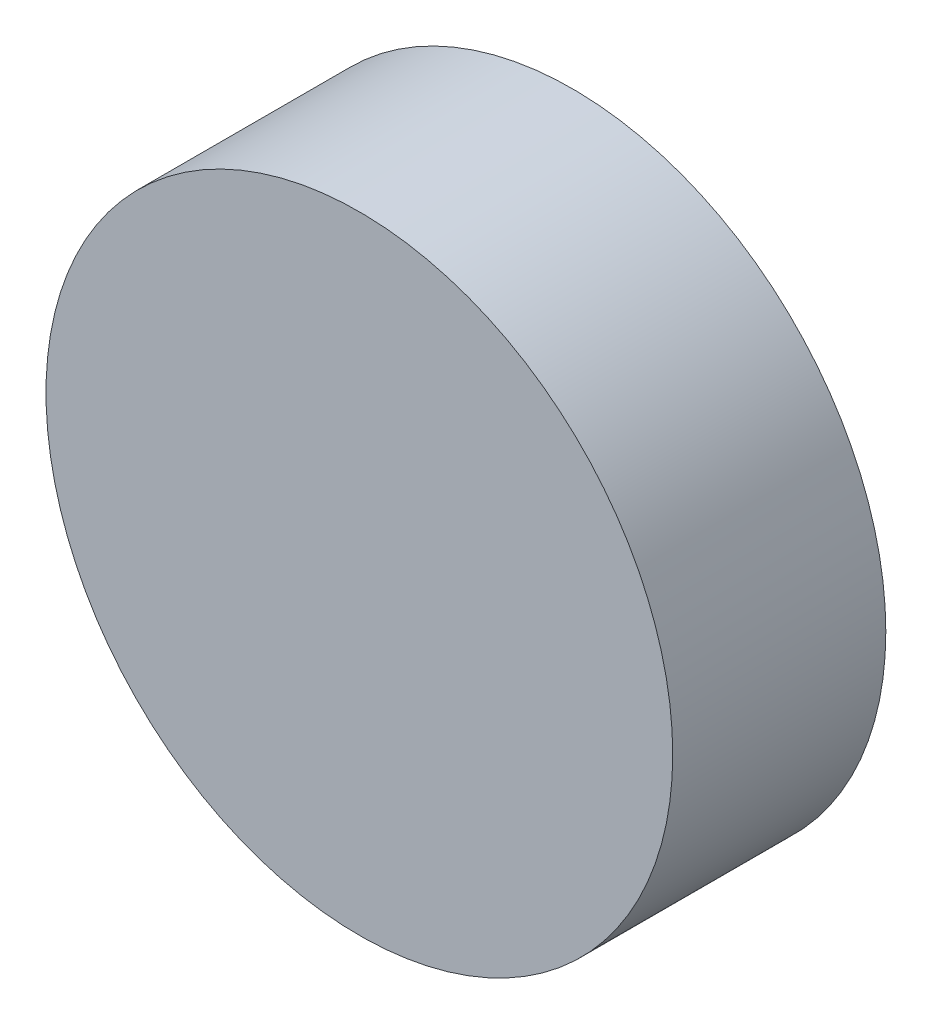
from build123d import *

# Parameters (mm, degrees)
SKETCH1_R           = 25
BOSS_EXTRUDE1_DEPTH = 17
CIRPATTERN1_COUNT   = 3
SKETCH14_W          = 15.649879363
SKETCH14_H          = 14
CUT_EXTRUDE2_DEPTH  = 17.25
CUT_EXTRUDE3_DEPTH  = 15
SKETCH16_R          = 2
SKETCH16_R_2        = 1
BOSS_EXTRUDE2_DEPTH = 3


with BuildPart() as part:
    # Sketch1 → Boss-Extrude1 (new body)
    with BuildSketch(Plane.XY):
        Circle(SKETCH1_R)
    extrude(amount=BOSS_EXTRUDE1_DEPTH)

    # Sketch12 → Ø3.0mm Dowel Hole1 (revolve, cut)
    with BuildSketch(Plane(origin=(0, 21, 0), x_dir=(0, 1, 0), z_dir=(1, 0, 0))):
        Polygon((0, 0), (0, 5.901290929), (1.5, 5), (1.5, 0), align=None)
    f_3_0mm_dowel_hole1 = revolve(axis=Axis((0, 21, -6.35), (0, 0, 1)), mode=Mode.SUBTRACT)

    # CirPattern1: Ø3.0mm Dowel Hole1 ×3 about axis
    cirpattern1_axis = Axis((0, 0, 0), (0, 0, 1))
    for i in range(1, CIRPATTERN1_COUNT):
        add(f_3_0mm_dowel_hole1.rotate(cirpattern1_axis, i * 360 / CIRPATTERN1_COUNT), mode=Mode.SUBTRACT)

    # Sketch14 → Cut-Extrude2 (cut)
    with BuildSketch(Plane(origin=(0, -25, 0), x_dir=(-1, 0, 0), z_dir=(0, -1, 0))):
        with Locations((-0.842506508, -8.397851159)):
            Rectangle(SKETCH14_W, SKETCH14_H)
    extrude(amount=-CUT_EXTRUDE2_DEPTH, mode=Mode.SUBTRACT)

    # Sketch15 → Cut-Extrude3 (cut)
    with BuildSketch(Plane(origin=(0, 0, 0), x_dir=(-1, 0, 0), z_dir=(0, 0, -1))):
        with BuildLine():
            ThreePointArc((-3.981818088, 20.619047619), (0, 17), (3.981818088, 20.619047619))
            ThreePointArc((3.981818088, 20.619047619), (18.186533479, 10.5), (19.847528084, -6.861168192))
            ThreePointArc((19.847528084, -6.861168192), (14.722431864, -8.5), (15.865709996, -13.757879427))
            ThreePointArc((15.865709996, -13.757879427), (0, -21), (-15.865709996, -13.757879427))
            ThreePointArc((-15.865709996, -13.757879427), (-14.722431864, -8.5), (-19.847528084, -6.861168192))
            ThreePointArc((-19.847528084, -6.861168192), (-18.186533479, 10.5), (-3.981818088, 20.619047619))
        make_face()
    extrude(amount=-CUT_EXTRUDE3_DEPTH, mode=Mode.SUBTRACT)

    # Sketch16 → Boss-Extrude2 (add)
    with BuildSketch(Plane(origin=(0, 0, 15), x_dir=(-1, 0, 0), z_dir=(0, 0, -1))):
        with Locations((-7, 8.038832814)):
            Circle(SKETCH16_R)
        with Locations((-7, 8.038832814)):
            Circle(SKETCH16_R_2, mode=Mode.SUBTRACT)
        with Locations((7, 8.038832814)):
            Circle(SKETCH16_R)
        with Locations((7, 8.038832814)):
            Circle(SKETCH16_R_2, mode=Mode.SUBTRACT)
    extrude(amount=BOSS_EXTRUDE2_DEPTH)


solid = part.part
